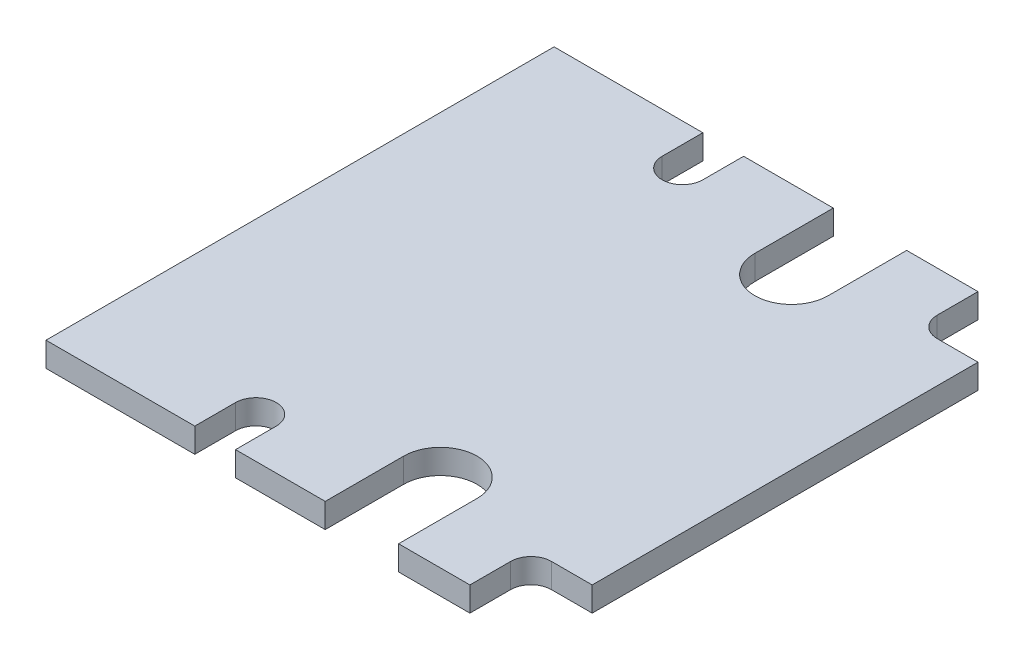
from build123d import *

# Parameters (mm, degrees)
BOSS_EXTRUDE1_DEPTH = 1.2
CUT_EXTRUDE2_DEPTH  = 2.2


with BuildPart() as part:
    # Sketch1 → Boss-Extrude1 (new body)
    with BuildSketch(Plane(origin=(0, 0, 0), x_dir=(1, 0, 0), z_dir=(0, 1, 0))):
        with BuildLine():
            Line((3.748031496, 8.025459318), (5.748031496, 8.025459318))
            Line((5.748031496, 8.025459318), (5.748031496, -10.904540682))
            Line((5.748031496, -10.904540682), (3.748031496, -10.904540682))
            ThreePointArc((3.748031496, -10.904540682), (3.040924715, -11.197433901), (2.748031496, -11.904540682))
            Line((2.748031496, -11.904540682), (2.748031496, -13.904540682))
            Line((2.748031496, -13.904540682), (-8.751968504, -13.904540682))
            Line((-8.751968504, -13.904540682), (-8.751968504, -11.904540682))
            ThreePointArc((-8.751968504, -11.904540682), (-9.751968504, -10.904540682), (-10.751968504, -11.904540682))
            Line((-10.751968504, -11.904540682), (-10.751968504, -13.904540682))
            Line((-10.751968504, -13.904540682), (-18.051968504, -13.904540682))
            Line((-18.051968504, -13.904540682), (-18.051968504, 11.025459318))
            Line((-18.051968504, 11.025459318), (-10.751968504, 11.025459318))
            Line((-10.751968504, 11.025459318), (-10.751968504, 9.025459318))
            ThreePointArc((-10.751968504, 9.025459318), (-9.751968504, 8.025459318), (-8.751968504, 9.025459318))
            Line((-8.751968504, 9.025459318), (-8.751968504, 11.025459318))
            Line((-8.751968504, 11.025459318), (2.748031496, 11.025459318))
            Line((2.748031496, 11.025459318), (2.748031496, 9.025459318))
            ThreePointArc((2.748031496, 9.025459318), (3.040924715, 8.318352536), (3.748031496, 8.025459318))
        make_face()
    extrude(amount=BOSS_EXTRUDE1_DEPTH)

    # Sketch2 → Cut-Extrude2 (cut, through all)
    with BuildSketch(Plane(origin=(0, 1.2, 0), x_dir=(1, 0, 0), z_dir=(0, 1, 0))):
        with BuildLine():
            Line((-4.351968504, 7.175459318), (-4.351968504, 11.025459318))
            Line((-4.351968504, 11.025459318), (-0.751968504, 11.025459318))
            Line((-0.751968504, 11.025459318), (-0.751968504, 7.175459318))
            ThreePointArc((-0.751968504, 7.175459318), (-2.551968504, 5.375459318), (-4.351968504, 7.175459318))
        make_face()
    cut_extrude2 = extrude(amount=-CUT_EXTRUDE2_DEPTH, mode=Mode.SUBTRACT)

    # Mirror2: Cut-Extrude2 across plane
    add(cut_extrude2.mirror(Plane.XY.offset(1.439540682)), mode=Mode.SUBTRACT)


solid = part.part
